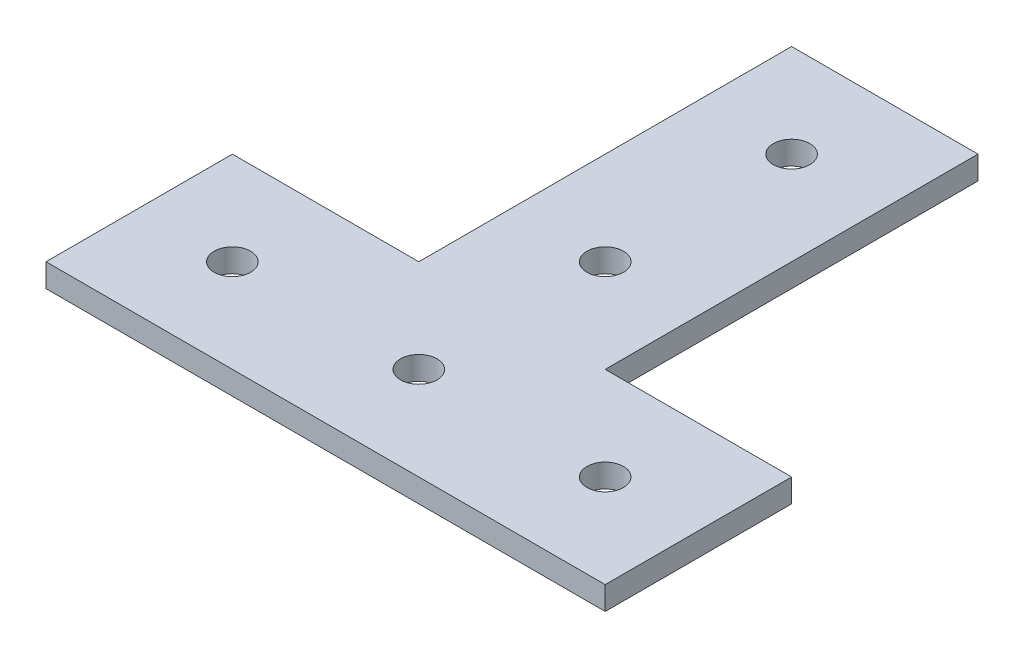
from build123d import *

# Parameters (mm, degrees)
SKETCH1_R           = 2.4892
BOSS_EXTRUDE1_DEPTH = 3.175


with BuildPart() as part:
    # Sketch1 → Boss-Extrude1 (new body)
    with BuildSketch(Plane(origin=(0, 0, 0), x_dir=(1, 0, 0), z_dir=(0, 1, 0))):
        Polygon((38.1, 0), (-38.1, 0), (-38.1, 25.4), (-12.7, 25.4), (-12.7, 76.2), (12.7, 76.2), (12.7, 25.4), (38.1, 25.4), align=None)
        with Locations((0, 63.5)):
            Circle(SKETCH1_R, mode=Mode.SUBTRACT)
        with Locations((0, 38.1)):
            Circle(SKETCH1_R, mode=Mode.SUBTRACT)
        with Locations((-25.4, 12.7)):
            Circle(SKETCH1_R, mode=Mode.SUBTRACT)
        with Locations((25.4, 12.7)):
            Circle(SKETCH1_R, mode=Mode.SUBTRACT)
        with Locations((0, 12.7)):
            Circle(SKETCH1_R, mode=Mode.SUBTRACT)
    extrude(amount=BOSS_EXTRUDE1_DEPTH)


solid = part.part
